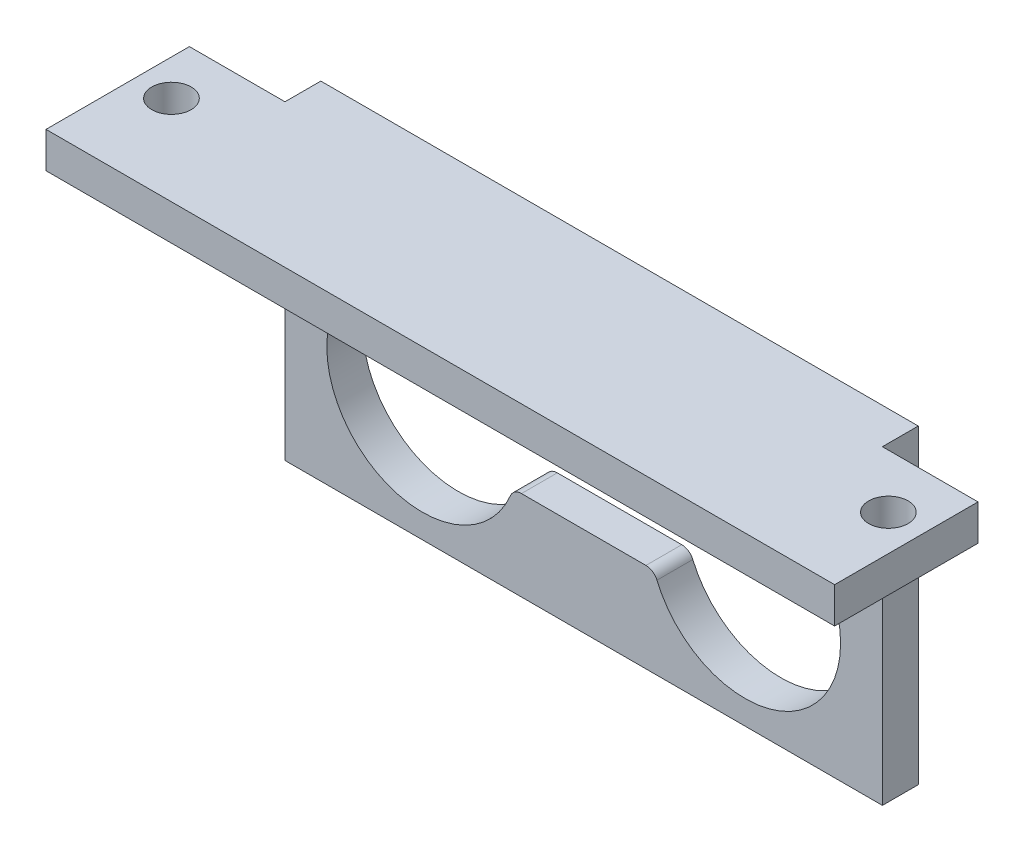
from build123d import *

# Parameters (mm, degrees)
SKETCH_1_W          = 50
SKETCH_1_H          = 20
EXTRUDE_1_DEPTH     = 3
SKETCH_2_W          = 50
SKETCH_2_H          = 15
EXTRUDE_2_DEPTH     = 6
SKETCH_5_W          = 50
SKETCH_5_H          = 12
CUT_EXTRUDE_2_DEPTH = 3
SKETCH_6_W          = 8
SKETCH_6_H          = 12
SKETCH_6_R          = 1.65
EXTRUDE_3_DEPTH     = 3


with BuildPart() as part:
    # 草图1 → 凸台-拉伸1 (new body)
    with BuildSketch(Plane.XY):
        Rectangle(SKETCH_1_W, SKETCH_1_H)
        with BuildLine():
            Line((-5.208438024, 2.5), (5.208438024, 2.5))
            ThreePointArc((5.208438024, 2.5), (5.761208823, 2.666666667), (6.129722688, 3.111111111))
            ThreePointArc((6.129722688, 3.111111111), (21.5, 0), (6.129722688, -3.111111111))
            ThreePointArc((6.129722688, -3.111111111), (5.761208823, -2.666666667), (5.208438024, -2.5))
            Line((5.208438024, -2.5), (-5.208438024, -2.5))
            ThreePointArc((-5.208438024, -2.5), (-5.761208823, -2.666666667), (-6.129722688, -3.111111111))
            ThreePointArc((-6.129722688, -3.111111111), (-21.5, 0), (-6.129722688, 3.111111111))
            ThreePointArc((-6.129722688, 3.111111111), (-5.761208823, 2.666666667), (-5.208438024, 2.5))
        make_face(mode=Mode.SUBTRACT)
        with BuildLine():
            Line((3.25, 5.5), (-3.25, 5.5))
            ThreePointArc((-3.25, 5.5), (-5, 7.25), (-3.25, 9))
            Line((-3.25, 9), (3.25, 9))
            ThreePointArc((3.25, 9), (5, 7.25), (3.25, 5.5))
        make_face(mode=Mode.SUBTRACT)
    extrude(amount=EXTRUDE_1_DEPTH)

    # 草图2 → 凸台-拉伸2 (add)
    with BuildSketch(Plane(origin=(0, 10, 0), x_dir=(1, 0, 0), z_dir=(0, 1, 0))):
        with Locations((0, -7.5)):
            Rectangle(SKETCH_2_W, SKETCH_2_H)
    extrude(amount=EXTRUDE_2_DEPTH)

    # 草图5 → 切除-拉伸2 (cut)
    with BuildSketch(Plane.XZ.offset(-10)):
        with Locations((0, 9)):
            Rectangle(SKETCH_5_W, SKETCH_5_H)
    extrude(amount=-CUT_EXTRUDE_2_DEPTH, mode=Mode.SUBTRACT)

    # 草图6 → 凸台-拉伸3 (add)
    with BuildSketch(Plane(origin=(0, 16, 0), x_dir=(1, 0, 0), z_dir=(0, 1, 0))):
        with Locations((29, -9)):
            Rectangle(SKETCH_6_W, SKETCH_6_H)
        with Locations((30, -7.5)):
            Circle(SKETCH_6_R, mode=Mode.SUBTRACT)
        with Locations((-29, -9)):
            Rectangle(SKETCH_6_W, SKETCH_6_H)
        with Locations((-30, -7.5)):
            Circle(SKETCH_6_R, mode=Mode.SUBTRACT)
    extrude(amount=-EXTRUDE_3_DEPTH)


solid = part.part
